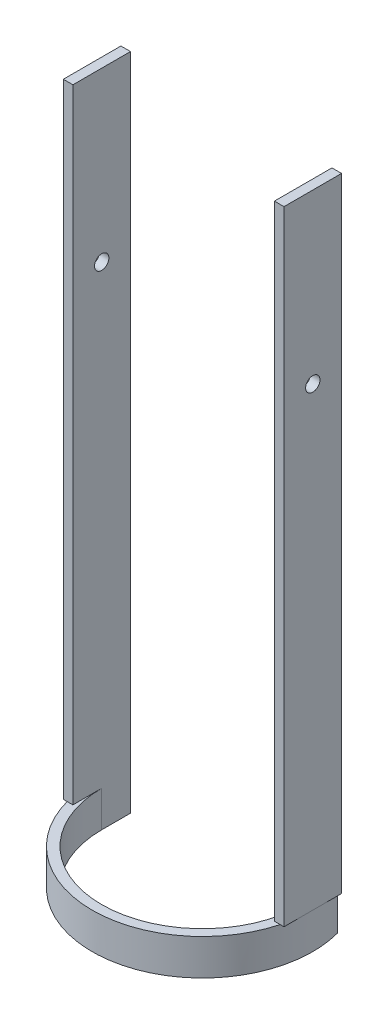
from build123d import *

# Parameters (mm, degrees)
EXTRUDE_1_DEPTH     = 30
SKETCH_4_W          = 4
SKETCH_4_H          = 24
EXTRUDE_3_DEPTH     = 260
SKETCH_7_W          = 149.597155604
SKETCH_7_H          = 115.941502163
CUT_EXTRUDE_3_DEPTH = 59
SKETCH_9_R          = 3
CUT_EXTRUDE_5_DEPTH = 93
SKETCH_10_R         = 50
SKETCH_10_R_2       = 46
CUT_EXTRUDE_6_DEPTH = 15


with BuildPart() as part:
    # 草图1 → 凸台-拉伸1 (new body)
    with BuildSketch(Plane(origin=(0, 0, 0), x_dir=(1, 0, 0), z_dir=(0, 1, 0))):
        with BuildLine():
            Line((-46, 0), (-46, 12))
            Line((-46, 12), (-42, 12))
            Line((-42, 12), (-42, 0))
            ThreePointArc((-42, 0), (0, -42), (42, 0))
            Line((42, 0), (42, 12))
            Line((42, 12), (46, 12))
            Line((46, 12), (46, 0))
            ThreePointArc((46, 0), (0, -46), (-46, 0))
        make_face()
    extrude(amount=EXTRUDE_1_DEPTH)

    # 草图4 → 凸台-拉伸3 (add)
    with BuildSketch(Plane(origin=(0, 30, 0), x_dir=(1, 0, 0), z_dir=(0, 1, 0))):
        with Locations((44, 0)):
            Rectangle(SKETCH_4_W, SKETCH_4_H)
        with Locations((-44, 0)):
            Rectangle(SKETCH_4_W, SKETCH_4_H)
    extrude(amount=EXTRUDE_3_DEPTH)

    # 草图7 → 切除-拉伸3 (cut, through all)
    with BuildSketch(Plane(origin=(0, 0, -12), x_dir=(-1, 0, 0), z_dir=(0, 0, -1))):
        with Locations((8.175952602, -42.970751082)):
            Rectangle(SKETCH_7_W, SKETCH_7_H)
    extrude(amount=-CUT_EXTRUDE_3_DEPTH, mode=Mode.SUBTRACT)

    # 草图9 → 切除-拉伸5 (cut, through all)
    with BuildSketch(Plane(origin=(46, 0, 0), x_dir=(0, 0, -1), z_dir=(1, 0, 0))):
        with Locations((0, 220)):
            Circle(SKETCH_9_R)
    extrude(amount=-CUT_EXTRUDE_5_DEPTH, mode=Mode.SUBTRACT)

    # 草图10 → 切除-拉伸6 (cut)
    with BuildSketch(Plane.XZ.offset(-15)):
        Circle(SKETCH_10_R)
        Circle(SKETCH_10_R_2, mode=Mode.SUBTRACT)
    extrude(amount=-CUT_EXTRUDE_6_DEPTH, mode=Mode.SUBTRACT)


solid = part.part
